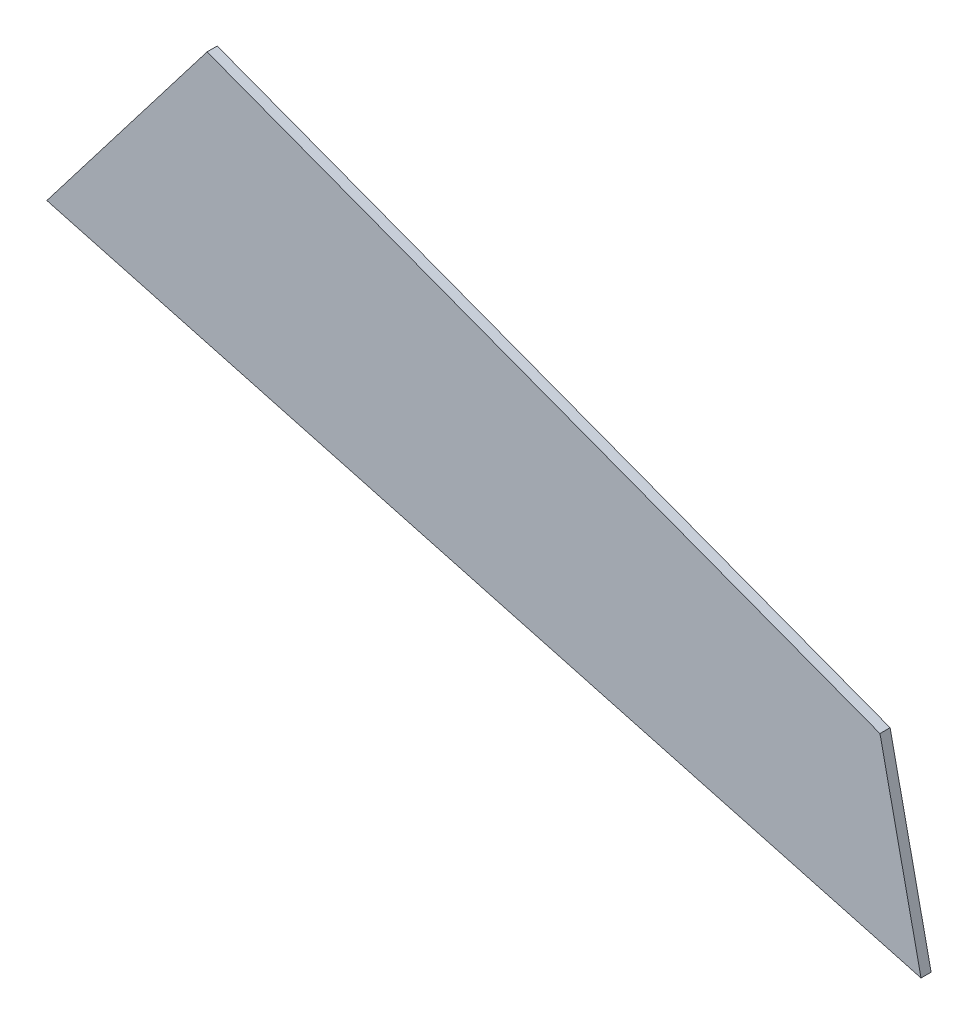
from build123d import *

# Parameters (mm, degrees)
BOSS_EXTRU_1_DEPTH = 3


with BuildPart() as part:
    # Esquisse1 → Boss.-Extru.1 (new body)
    with BuildSketch(Plane.XY):
        Polygon((-484.489325307, 49.927847112), (-436.988244517, 111.846536808), (-237.514047494, 36.56942714), (-225.340182798, -20.106592227), align=None)
    extrude(amount=BOSS_EXTRU_1_DEPTH)


solid = part.part
